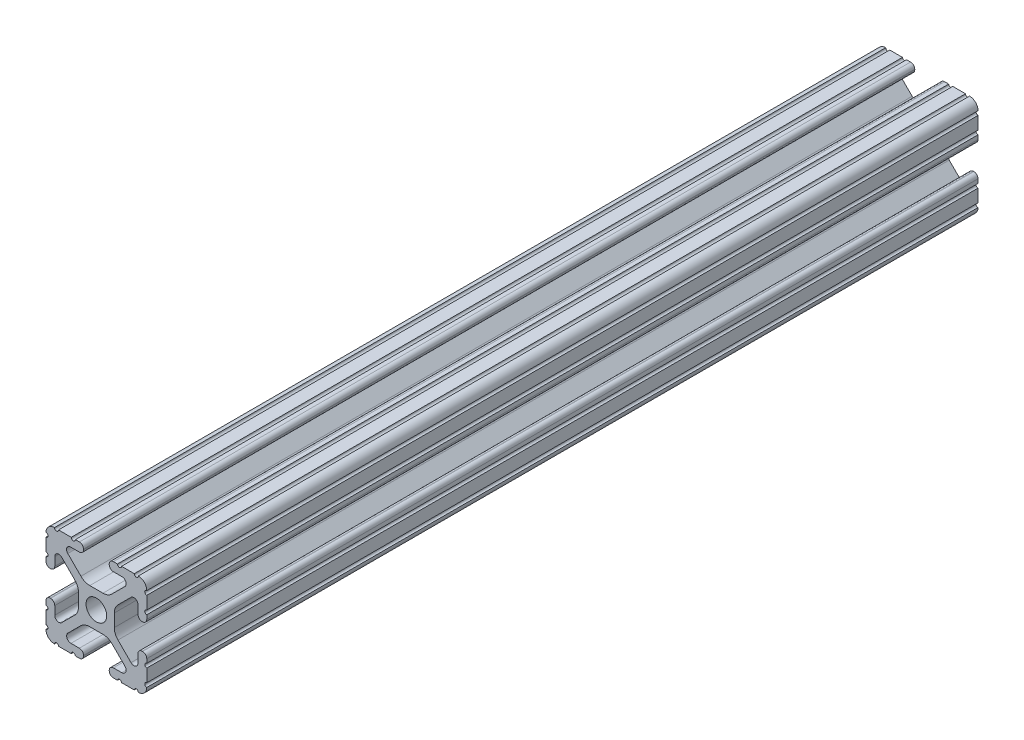
from build123d import *

# Parameters (mm, degrees)
SKETCH1_R               = 2.6035
BOSS_EXTRUDE1_DEPTH     = 104.775
SKETCH2_R               = 3.175
CUT_EXTRUDE1_DEPTH      = 107.933559572
CUT_EXTRUDE1_DEPTH_BACK = 107.933559572


with BuildPart() as part:
    # Sketch1 → Boss-Extrude1 (new, symmetric)
    with BuildSketch(Plane.XY):
        with BuildLine():
            Line((-7.179650497, -8.645192506), (-3.952270251, -5.423690499))
            ThreePointArc((-3.952270251, -5.423690499), (-2.922936451, -4.736929036), (-1.709253557, -4.4958))
            Line((-1.709253557, -4.4958), (1.709253557, -4.4958))
            ThreePointArc((1.709253557, -4.4958), (2.922936451, -4.736929036), (3.952270251, -5.423690499))
            Line((3.952270251, -5.423690499), (7.179650497, -8.645192506))
            ThreePointArc((7.179650497, -8.645192506), (7.41473083, -9.822813117), (6.416408329, -10.4902))
            Line((6.416408329, -10.4902), (4.287512407, -10.4902))
            ThreePointArc((4.287512407, -10.4902), (3.54574862, -10.79744862), (3.2385, -11.539212407))
            Line((3.2385, -11.539212407), (3.2385, -11.650987593))
            ThreePointArc((3.2385, -11.650987593), (3.54574862, -12.39275138), (4.287512407, -12.7))
            Line((4.287512407, -12.7), (5.317126718, -12.7))
            ThreePointArc((5.317126718, -12.7), (5.825126718, -12.192), (6.333126718, -12.7))
            Line((6.333126718, -12.7), (9.550443118, -12.7))
            ThreePointArc((9.550443118, -12.7), (10.058366869, -12.192000006), (10.566443095, -12.699847501))
            ThreePointArc((10.566443095, -12.699847501), (12.082537762, -12.08250727), (12.699846982, -10.566399977))
            ThreePointArc((12.699846982, -10.566399977), (12.192000006, -10.058323491), (12.7, -9.5504))
            Line((12.7, -9.5504), (12.7, -6.3330836))
            ThreePointArc((12.7, -6.3330836), (12.192, -5.8250836), (12.7, -5.3170836))
            Line((12.7, -5.3170836), (12.7, -4.287469289))
            ThreePointArc((12.7, -4.287469289), (12.39275138, -3.545705502), (11.650987593, -3.238456882))
            Line((11.650987593, -3.238456882), (11.539212407, -3.238456882))
            ThreePointArc((11.539212407, -3.238456882), (10.79744862, -3.545705502), (10.4902, -4.287469289))
            Line((10.4902, -4.287469289), (10.4902, -6.402089023))
            ThreePointArc((10.4902, -6.402089023), (9.856505071, -7.351067942), (8.737131347, -7.129408934))
            Line((8.737131347, -7.129408934), (5.441005833, -3.840816462))
            ThreePointArc((5.441005833, -3.840816462), (4.750877967, -2.809883091), (4.5085, -1.593185507))
            Line((4.5085, -1.593185507), (4.5085, 1.593185507))
            ThreePointArc((4.5085, 1.593185507), (4.750877967, 2.809883091), (5.441005833, 3.840816462))
            Line((5.441005833, 3.840816462), (8.737131347, 7.129408934))
            ThreePointArc((8.737131347, 7.129408934), (9.856505071, 7.351067942), (10.4902, 6.402089023))
            Line((10.4902, 6.402089023), (10.4902, 4.287469289))
            ThreePointArc((10.4902, 4.287469289), (10.79744862, 3.545705502), (11.539212407, 3.238456882))
            Line((11.539212407, 3.238456882), (11.650987593, 3.238456882))
            ThreePointArc((11.650987593, 3.238456882), (12.39275138, 3.545705502), (12.7, 4.287469289))
            Line((12.7, 4.287469289), (12.7, 5.3170836))
            ThreePointArc((12.7, 5.3170836), (12.192, 5.8250836), (12.7, 6.3330836))
            Line((12.7, 6.3330836), (12.7, 9.5504))
            ThreePointArc((12.7, 9.5504), (12.192000006, 10.058323491), (12.699846982, 10.566399977))
            ThreePointArc((12.699846982, 10.566399977), (12.082537762, 12.08250727), (10.566443095, 12.699847501))
            ThreePointArc((10.566443095, 12.699847501), (10.058366869, 12.192000006), (9.550443118, 12.7))
            Line((9.550443118, 12.7), (6.333126718, 12.7))
            ThreePointArc((6.333126718, 12.7), (5.825126718, 12.192), (5.317126718, 12.7))
            Line((5.317126718, 12.7), (4.287512407, 12.7))
            ThreePointArc((4.287512407, 12.7), (3.54574862, 12.39275138), (3.2385, 11.650987593))
            Line((3.2385, 11.650987593), (3.2385, 11.539212407))
            ThreePointArc((3.2385, 11.539212407), (3.54574862, 10.79744862), (4.287512407, 10.4902))
            Line((4.287512407, 10.4902), (6.476788598, 10.4902))
            ThreePointArc((6.476788598, 10.4902), (7.432222385, 9.85140422), (7.207036008, 8.724370562))
            Line((7.207036008, 8.724370562), (3.898272566, 5.423169045))
            ThreePointArc((3.898272566, 5.423169045), (2.869120213, 4.736787962), (1.655778399, 4.4958))
            Line((1.655778399, 4.4958), (-1.655778399, 4.4958))
            ThreePointArc((-1.655778399, 4.4958), (-2.869120213, 4.736787962), (-3.898272566, 5.423169045))
            Line((-3.898272566, 5.423169045), (-7.207036008, 8.724370562))
            ThreePointArc((-7.207036008, 8.724370562), (-7.432222385, 9.85140422), (-6.476788598, 10.4902))
            Line((-6.476788598, 10.4902), (-4.287512407, 10.4902))
            ThreePointArc((-4.287512407, 10.4902), (-3.54574862, 10.79744862), (-3.2385, 11.539212407))
            Line((-3.2385, 11.539212407), (-3.2385, 11.650987593))
            ThreePointArc((-3.2385, 11.650987593), (-3.54574862, 12.39275138), (-4.287512407, 12.7))
            Line((-4.287512407, 12.7), (-5.317126718, 12.7))
            ThreePointArc((-5.317126718, 12.7), (-5.825126718, 12.192), (-6.333126718, 12.7))
            Line((-6.333126718, 12.7), (-9.550443118, 12.7))
            ThreePointArc((-9.550443118, 12.7), (-10.058366869, 12.192000006), (-10.566443095, 12.699847501))
            ThreePointArc((-10.566443095, 12.699847501), (-12.082537762, 12.08250727), (-12.699846982, 10.566399977))
            ThreePointArc((-12.699846982, 10.566399977), (-12.192000006, 10.058323491), (-12.7, 9.5504))
            Line((-12.7, 9.5504), (-12.7, 6.3330836))
            ThreePointArc((-12.7, 6.3330836), (-12.192, 5.8250836), (-12.7, 5.3170836))
            Line((-12.7, 5.3170836), (-12.7, 4.287469289))
            ThreePointArc((-12.7, 4.287469289), (-12.39275138, 3.545705502), (-11.650987593, 3.238456882))
            Line((-11.650987593, 3.238456882), (-11.539212407, 3.238456882))
            ThreePointArc((-11.539212407, 3.238456882), (-10.79744862, 3.545705502), (-10.4902, 4.287469289))
            Line((-10.4902, 4.287469289), (-10.4902, 6.402089023))
            ThreePointArc((-10.4902, 6.402089023), (-9.856505071, 7.351067942), (-8.737131347, 7.129408934))
            Line((-8.737131347, 7.129408934), (-5.441005833, 3.840816462))
            ThreePointArc((-5.441005833, 3.840816462), (-4.750877967, 2.809883091), (-4.5085, 1.593185507))
            Line((-4.5085, 1.593185507), (-4.5085, -1.593185507))
            ThreePointArc((-4.5085, -1.593185507), (-4.750877967, -2.809883091), (-5.441005833, -3.840816462))
            Line((-5.441005833, -3.840816462), (-8.737131347, -7.129408934))
            ThreePointArc((-8.737131347, -7.129408934), (-9.856505071, -7.351067942), (-10.4902, -6.402089023))
            Line((-10.4902, -6.402089023), (-10.4902, -4.287469289))
            ThreePointArc((-10.4902, -4.287469289), (-10.79744862, -3.545705502), (-11.539212407, -3.238456882))
            Line((-11.539212407, -3.238456882), (-11.650987593, -3.238456882))
            ThreePointArc((-11.650987593, -3.238456882), (-12.39275138, -3.545705502), (-12.7, -4.287469289))
            Line((-12.7, -4.287469289), (-12.7, -5.3170836))
            ThreePointArc((-12.7, -5.3170836), (-12.192, -5.8250836), (-12.7, -6.3330836))
            Line((-12.7, -6.3330836), (-12.7, -9.5504))
            ThreePointArc((-12.7, -9.5504), (-12.192000006, -10.058323491), (-12.699846982, -10.566399977))
            ThreePointArc((-12.699846982, -10.566399977), (-12.082537762, -12.08250727), (-10.566443095, -12.699847501))
            ThreePointArc((-10.566443095, -12.699847501), (-10.058366869, -12.192000006), (-9.550443118, -12.7))
            Line((-9.550443118, -12.7), (-6.333126718, -12.7))
            ThreePointArc((-6.333126718, -12.7), (-5.825126718, -12.192), (-5.317126718, -12.7))
            Line((-5.317126718, -12.7), (-4.287512407, -12.7))
            ThreePointArc((-4.287512407, -12.7), (-3.54574862, -12.39275138), (-3.2385, -11.650987593))
            Line((-3.2385, -11.650987593), (-3.2385, -11.539212407))
            ThreePointArc((-3.2385, -11.539212407), (-3.54574862, -10.79744862), (-4.287512407, -10.4902))
            Line((-4.287512407, -10.4902), (-6.416408329, -10.4902))
            ThreePointArc((-6.416408329, -10.4902), (-7.41473083, -9.822813117), (-7.179650497, -8.645192506))
        make_face()
        Circle(SKETCH1_R, mode=Mode.SUBTRACT)
    extrude(amount=BOSS_EXTRUDE1_DEPTH, both=True)

    # Sketch2 → Cut-Extrude1 (cut, two sides)
    with BuildSketch(Plane(origin=(0, 4.4958, 0), x_dir=(1, 0, 0), z_dir=(0, 1, 0))) as cut_extrude1_sk:
        with Locations(Location((0, 92.075, 0), (0, 0, 122.571221948))):
            Circle(SKETCH2_R)
    extrude(amount=CUT_EXTRUDE1_DEPTH, mode=Mode.SUBTRACT)
    extrude(cut_extrude1_sk.sketch, amount=-CUT_EXTRUDE1_DEPTH_BACK, mode=Mode.SUBTRACT)


solid = part.part
